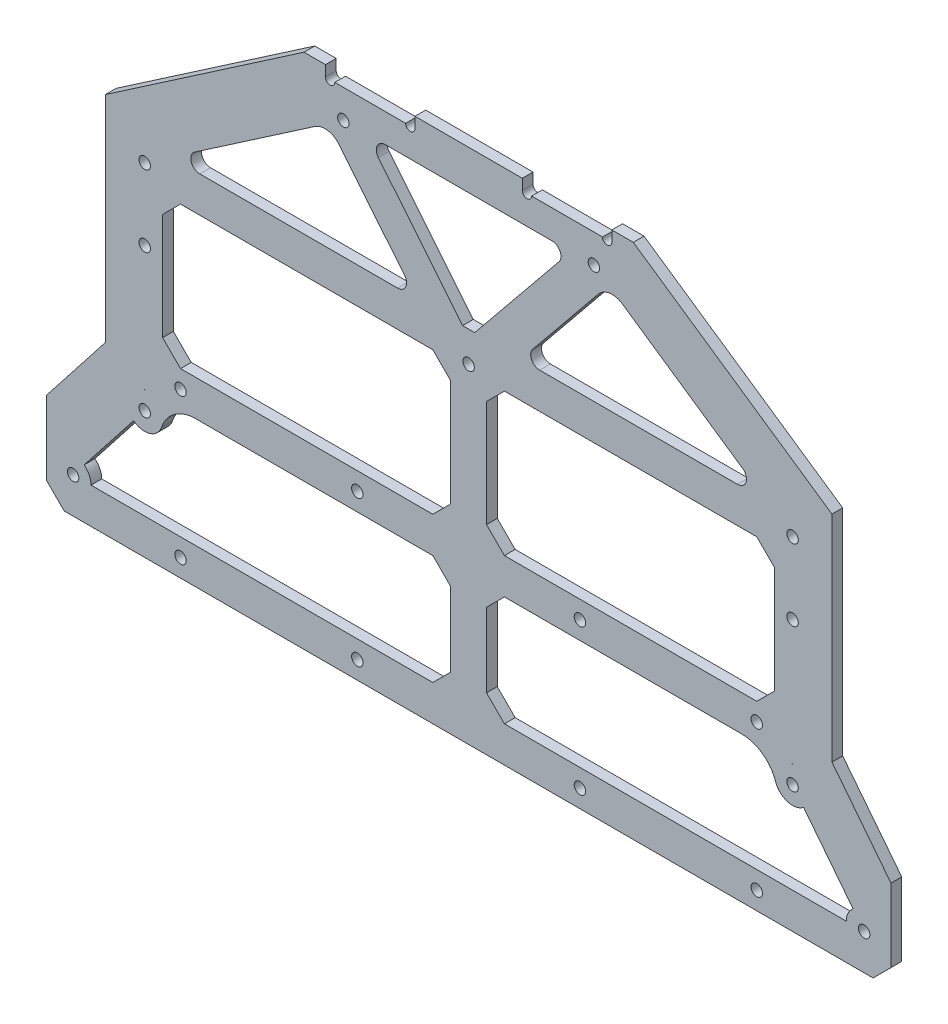
from build123d import *

# Parameters (mm, degrees)
SKETCH_1_R           = 1.6
EXTRUDE_1_DEPTH      = 3
EXTRUDE_2_DEPTH      = 3
CUT_EXTRUDE_2_REACH  = 5
SKETCH_6_W           = 3
SKETCH_6_H           = 46.5
CUT_EXTRUDE_3_DEPTH  = 3.5
SKETCH_7_W           = 3
SKETCH_7_H           = 46.5
CUT_EXTRUDE_4_DEPTH  = 3.5
CUT_EXTRUDE_5_REACH  = 5
CUT_EXTRUDE_6_REACH  = 5
SKETCH_11_W          = 181
SKETCH_11_H          = 10
EXTRUDE_2_2_DEPTH    = 3
CUT_EXTRUDE_7_REACH  = 5
SKETCH_12_R          = 1.6
EXTRUDE_4_DEPTH      = 3
CUT_EXTRUDE_8_REACH  = 5
SKETCH_15_W          = 10
SKETCH_15_H          = 100.5
EXTRUDE_5_DEPTH      = 3
CUT_EXTRUDE_9_REACH  = 5
SKETCH_16_R          = 1.6
SKETCH_17_W          = 181
SKETCH_17_H          = 10
EXTRUDE_6_DEPTH      = 3
CUT_EXTRUDE_10_REACH = 5
SKETCH_18_R          = 1.6
CUT_EXTRUDE_11_REACH = 5
SKETCH_19_R          = 1.6
EXTRUDE_3_DEPTH      = 3
FILLET_1_R           = 10
CHAMFER_1_SIZE       = 5
CHAMFER_2_SIZE       = 5
CUT_EXTRUDE_12_REACH = 5
CUT_EXTRUDE_13_REACH = 5
SKETCH_22_R          = 1.6
FILLET_2_R           = 5
FILLET_3_R           = 2.5
EXTRUDE_4_2_DEPTH    = 3
CUT_EXTRUDE_14_REACH = 5
SKETCH_24_R          = 1.6
CHAMFER_3_SIZE       = 5


with BuildPart() as part:
    # 草图1 → 凸台-拉伸1 (new body)
    with BuildSketch(Plane.XY):
        Polygon((-121.5, -87), (-121.5, -123.5), (-121.5, -133.5), (121.5, -133.5), (121.5, -123.5), (121.5, -87), (101.5, -87), (101.5, -27), (46, -27), (46, 11), (-46, 11), (-46, -27), (-101.5, -27), (-101.5, -87), align=None)
        with Locations((-110.5, -123.5)):
            Circle(SKETCH_1_R, mode=Mode.SUBTRACT)
        with Locations((-90.5, -98)):
            Circle(SKETCH_1_R, mode=Mode.SUBTRACT)
        with Locations((-90.5, -38)):
            Circle(SKETCH_1_R, mode=Mode.SUBTRACT)
        with Locations((-35, 0)):
            Circle(SKETCH_1_R, mode=Mode.SUBTRACT)
        with Locations((110.5, -123.5)):
            Circle(SKETCH_1_R, mode=Mode.SUBTRACT)
        with Locations((90.5, -98)):
            Circle(SKETCH_1_R, mode=Mode.SUBTRACT)
        with Locations((90.5, -38)):
            Circle(SKETCH_1_R, mode=Mode.SUBTRACT)
        with Locations((35, 0)):
            Circle(SKETCH_1_R, mode=Mode.SUBTRACT)
    extrude(amount=EXTRUDE_1_DEPTH)

    # 草图4 → Extrude 2 (add)
    with BuildSketch(Plane(origin=(0, 0, 0), x_dir=(-1, 0, 0), z_dir=(0, 0, -1))):
        Polygon((-101.5, -27), (-46, 11), (-46, -27), align=None)
        Polygon((46, 11), (101.5, -27), (46, -27), align=None)
    extrude(amount=-EXTRUDE_2_DEPTH)

    # 草图5 → 切除-拉伸2 (cut, up to next)
    with BuildSketch(Plane.XY.offset(3), mode=Mode.PRIVATE) as cut_extrude_2_sk1:
        with BuildLine():
            Line((-86.374375572, -35.175248139), (-39.125624428, -2.824751861))
            ThreePointArc((-39.125624428, -2.824751861), (-33.521507887, -4.776406711), (-30, 0))
            Line((-30, 0), (30, 0))
            ThreePointArc((30, 0), (33.521507887, -4.776406711), (39.125624428, -2.824751861))
            Line((39.125624428, -2.824751861), (86.374375572, -35.175248139))
            ThreePointArc((86.374375572, -35.175248139), (86.077118626, -40.331977776), (90.5, -43))
            Line((90.5, -43), (90.5, -93))
            ThreePointArc((90.5, -93), (85.773937398, -99.632278249), (93.585699676, -101.934267087))
            Line((93.585699676, -101.934267087), (107.414300324, -119.565732913))
            ThreePointArc((107.414300324, -119.565732913), (106.003974067, -121.312364105), (105.5, -123.5))
            Line((105.5, -123.5), (-105.5, -123.5))
            ThreePointArc((-105.5, -123.5), (-106.003974067, -121.312364105), (-107.414300324, -119.565732913))
            Line((-107.414300324, -119.565732913), (-93.585699676, -101.934267087))
            ThreePointArc((-93.585699676, -101.934267087), (-85.773937398, -99.632278249), (-90.5, -93))
            Line((-90.5, -93), (-90.5, -43))
            ThreePointArc((-90.5, -43), (-86.077118626, -40.331977776), (-86.374375572, -35.175248139))
        make_face()
    cut_extrude_2_tool1 = extrude(cut_extrude_2_sk1.sketch, amount=-CUT_EXTRUDE_2_REACH, mode=Mode.PRIVATE) & part.part
    add(cut_extrude_2_tool1.solids().sort_by_distance((0, -68.124521, 3))[0], mode=Mode.SUBTRACT)

    # 草图6 → 切除-拉伸3 (cut)
    with BuildSketch(Plane.ZY.offset(121.5)):
        with Locations((1.5, -110.25)):
            Rectangle(SKETCH_6_W, SKETCH_6_H)
    extrude(amount=-CUT_EXTRUDE_3_DEPTH, mode=Mode.SUBTRACT)

    # 草图7 → 切除-拉伸4 (cut)
    with BuildSketch(Plane(origin=(121.5, 0, 0), x_dir=(0, 0, -1), z_dir=(1, 0, 0))):
        with Locations((-1.5, -110.25)):
            Rectangle(SKETCH_7_W, SKETCH_7_H)
    extrude(amount=-CUT_EXTRUDE_4_DEPTH, mode=Mode.SUBTRACT)

    # 草图8 → 切除-拉伸5 (cut, up to next)
    with BuildSketch(Plane.XY.offset(3), mode=Mode.PRIVATE) as cut_extrude_5_sk1:
        Polygon((-101.5, -87), (-118, -108.0375), (-118, -87), align=None)
    cut_extrude_5_tool1 = extrude(cut_extrude_5_sk1.sketch, amount=-CUT_EXTRUDE_5_REACH, mode=Mode.PRIVATE) & part.part
    add(cut_extrude_5_tool1.solids().sort_by_distance((-112.5, -94.0125, 3))[0], mode=Mode.SUBTRACT)

    # 草图9 → 切除-拉伸6 (cut, up to next)
    with BuildSketch(Plane.XY.offset(3), mode=Mode.PRIVATE) as cut_extrude_6_sk1:
        Polygon((101.5, -87), (118, -108.0375), (118, -87), align=None)
    cut_extrude_6_tool1 = extrude(cut_extrude_6_sk1.sketch, amount=-CUT_EXTRUDE_6_REACH, mode=Mode.PRIVATE) & part.part
    add(cut_extrude_6_tool1.solids().sort_by_distance((112.5, -94.0125, 3))[0], mode=Mode.SUBTRACT)

    # 草图11 → Extrude 2 2 (add)
    with BuildSketch(Plane.XY.offset(3)):
        with Locations((0, -38)):
            Rectangle(SKETCH_11_W, SKETCH_11_H)
    extrude(amount=-EXTRUDE_2_2_DEPTH)

    # 草图12 → 切除-拉伸7 (cut, up to next)
    with BuildSketch(Plane(origin=(0, 0, 0), x_dir=(-1, 0, 0), z_dir=(0, 0, -1)), mode=Mode.PRIVATE) as cut_extrude_7_sk1:
        with Locations((-90.5, -38)):
            Circle(SKETCH_12_R)
    cut_extrude_7_tool1 = extrude(cut_extrude_7_sk1.sketch, amount=-CUT_EXTRUDE_7_REACH, mode=Mode.PRIVATE) & part.part
    add(cut_extrude_7_tool1.solids().sort_by_distance((90.5, -38, 0))[0], mode=Mode.SUBTRACT)
    # 草图12 → 切除-拉伸7 (cut, up to next)
    with BuildSketch(Plane(origin=(0, 0, 0), x_dir=(-1, 0, 0), z_dir=(0, 0, -1)), mode=Mode.PRIVATE) as cut_extrude_7_sk2:
        with Locations((90.5, -38)):
            Circle(SKETCH_12_R)
    cut_extrude_7_tool2 = extrude(cut_extrude_7_sk2.sketch, amount=-CUT_EXTRUDE_7_REACH, mode=Mode.PRIVATE) & part.part
    add(cut_extrude_7_tool2.solids().sort_by_distance((-90.5, -38, 0))[0], mode=Mode.SUBTRACT)

    # 草图13 → Extrude 4 (add)
    with BuildSketch(Plane(origin=(0, 0, 0), x_dir=(-1, 0, 0), z_dir=(0, 0, -1))):
        Polygon((-38.877810019, -3.156356992), (0, -50.920523586), (38.877810019, -3.156356992), (31.122189981, 3.156356992), (0, -35.079476414), (-31.122189981, 3.156356992), align=None)
    extrude(amount=-EXTRUDE_4_DEPTH)

    # 草图14 → 切除-拉伸8 (cut, up to next)
    with BuildSketch(Plane.XY.offset(3), mode=Mode.PRIVATE) as cut_extrude_8_sk1:
        Polygon((0, -50.920523586), (6.446937803, -43), (-6.446937803, -43), align=None)
    cut_extrude_8_tool1 = extrude(cut_extrude_8_sk1.sketch, amount=-CUT_EXTRUDE_8_REACH, mode=Mode.PRIVATE) & part.part
    add(cut_extrude_8_tool1.solids().sort_by_distance((0, -45.640175, 3))[0], mode=Mode.SUBTRACT)

    # 草图15 → 拉伸-薄壁5 (add)
    with BuildSketch(Plane.XY.offset(3)):
        with Locations((0, -83.25)):
            Rectangle(SKETCH_15_W, SKETCH_15_H)
    extrude(amount=-EXTRUDE_5_DEPTH)

    # 草图16 → 切除-拉伸9 (cut, up to next)
    with BuildSketch(Plane(origin=(0, 0, 0), x_dir=(-1, 0, 0), z_dir=(0, 0, -1)), mode=Mode.PRIVATE) as cut_extrude_9_sk1:
        with Locations((80.5, -128.5)):
            Circle(SKETCH_16_R)
    cut_extrude_9_tool1 = extrude(cut_extrude_9_sk1.sketch, amount=-CUT_EXTRUDE_9_REACH, mode=Mode.PRIVATE) & part.part
    add(cut_extrude_9_tool1.solids().sort_by_distance((-80.5, -128.5, 0))[0], mode=Mode.SUBTRACT)
    # 草图16 → 切除-拉伸9 (cut, up to next)
    with BuildSketch(Plane(origin=(0, 0, 0), x_dir=(-1, 0, 0), z_dir=(0, 0, -1)), mode=Mode.PRIVATE) as cut_extrude_9_sk2:
        with Locations((31.1, -128.5)):
            Circle(SKETCH_16_R)
    cut_extrude_9_tool2 = extrude(cut_extrude_9_sk2.sketch, amount=-CUT_EXTRUDE_9_REACH, mode=Mode.PRIVATE) & part.part
    add(cut_extrude_9_tool2.solids().sort_by_distance((-31.1, -128.5, 0))[0], mode=Mode.SUBTRACT)
    # 草图16 → 切除-拉伸9 (cut, up to next)
    with BuildSketch(Plane(origin=(0, 0, 0), x_dir=(-1, 0, 0), z_dir=(0, 0, -1)), mode=Mode.PRIVATE) as cut_extrude_9_sk3:
        with Locations((-80.5, -128.5)):
            Circle(SKETCH_16_R)
    cut_extrude_9_tool3 = extrude(cut_extrude_9_sk3.sketch, amount=-CUT_EXTRUDE_9_REACH, mode=Mode.PRIVATE) & part.part
    add(cut_extrude_9_tool3.solids().sort_by_distance((80.5, -128.5, 0))[0], mode=Mode.SUBTRACT)
    # 草图16 → 切除-拉伸9 (cut, up to next)
    with BuildSketch(Plane(origin=(0, 0, 0), x_dir=(-1, 0, 0), z_dir=(0, 0, -1)), mode=Mode.PRIVATE) as cut_extrude_9_sk4:
        with Locations((-31.1, -128.5)):
            Circle(SKETCH_16_R)
    cut_extrude_9_tool4 = extrude(cut_extrude_9_sk4.sketch, amount=-CUT_EXTRUDE_9_REACH, mode=Mode.PRIVATE) & part.part
    add(cut_extrude_9_tool4.solids().sort_by_distance((31.1, -128.5, 0))[0], mode=Mode.SUBTRACT)

    # 草图17 → 拉伸-薄壁6 (add)
    with BuildSketch(Plane(origin=(0, 0, 0), x_dir=(-1, 0, 0), z_dir=(0, 0, -1))):
        with Locations((0, -87.8)):
            Rectangle(SKETCH_17_W, SKETCH_17_H)
    extrude(amount=-EXTRUDE_6_DEPTH)

    # 草图18 → 切除-拉伸10 (cut, up to next)
    with BuildSketch(Plane(origin=(0, 0, 0), x_dir=(-1, 0, 0), z_dir=(0, 0, -1)), mode=Mode.PRIVATE) as cut_extrude_10_sk1:
        with Locations((31.1, -87.8)):
            Circle(SKETCH_18_R)
    cut_extrude_10_tool1 = extrude(cut_extrude_10_sk1.sketch, amount=-CUT_EXTRUDE_10_REACH, mode=Mode.PRIVATE) & part.part
    add(cut_extrude_10_tool1.solids().sort_by_distance((-31.1, -87.8, 0))[0], mode=Mode.SUBTRACT)
    # 草图18 → 切除-拉伸10 (cut, up to next)
    with BuildSketch(Plane(origin=(0, 0, 0), x_dir=(-1, 0, 0), z_dir=(0, 0, -1)), mode=Mode.PRIVATE) as cut_extrude_10_sk2:
        with Locations((80.5, -87.8)):
            Circle(SKETCH_18_R)
    cut_extrude_10_tool2 = extrude(cut_extrude_10_sk2.sketch, amount=-CUT_EXTRUDE_10_REACH, mode=Mode.PRIVATE) & part.part
    add(cut_extrude_10_tool2.solids().sort_by_distance((-80.5, -87.8, 0))[0], mode=Mode.SUBTRACT)
    # 草图18 → 切除-拉伸10 (cut, up to next)
    with BuildSketch(Plane(origin=(0, 0, 0), x_dir=(-1, 0, 0), z_dir=(0, 0, -1)), mode=Mode.PRIVATE) as cut_extrude_10_sk3:
        with Locations((-80.5, -87.8)):
            Circle(SKETCH_18_R)
    cut_extrude_10_tool3 = extrude(cut_extrude_10_sk3.sketch, amount=-CUT_EXTRUDE_10_REACH, mode=Mode.PRIVATE) & part.part
    add(cut_extrude_10_tool3.solids().sort_by_distance((80.5, -87.8, 0))[0], mode=Mode.SUBTRACT)
    # 草图18 → 切除-拉伸10 (cut, up to next)
    with BuildSketch(Plane(origin=(0, 0, 0), x_dir=(-1, 0, 0), z_dir=(0, 0, -1)), mode=Mode.PRIVATE) as cut_extrude_10_sk4:
        with Locations((-31.1, -87.8)):
            Circle(SKETCH_18_R)
    cut_extrude_10_tool4 = extrude(cut_extrude_10_sk4.sketch, amount=-CUT_EXTRUDE_10_REACH, mode=Mode.PRIVATE) & part.part
    add(cut_extrude_10_tool4.solids().sort_by_distance((31.1, -87.8, 0))[0], mode=Mode.SUBTRACT)

    # 草图19 → 切除-拉伸11 (cut, up to next)
    with BuildSketch(Plane(origin=(0, 0, 0), x_dir=(-1, 0, 0), z_dir=(0, 0, -1)), mode=Mode.PRIVATE) as cut_extrude_11_sk1:
        with Locations((-35, 0)):
            Circle(SKETCH_19_R)
    cut_extrude_11_tool1 = extrude(cut_extrude_11_sk1.sketch, amount=-CUT_EXTRUDE_11_REACH, mode=Mode.PRIVATE) & part.part
    add(cut_extrude_11_tool1.solids().sort_by_distance((35, 0, 0))[0], mode=Mode.SUBTRACT)
    # 草图19 → 切除-拉伸11 (cut, up to next)
    with BuildSketch(Plane(origin=(0, 0, 0), x_dir=(-1, 0, 0), z_dir=(0, 0, -1)), mode=Mode.PRIVATE) as cut_extrude_11_sk2:
        with Locations((35, 0)):
            Circle(SKETCH_19_R)
    cut_extrude_11_tool2 = extrude(cut_extrude_11_sk2.sketch, amount=-CUT_EXTRUDE_11_REACH, mode=Mode.PRIVATE) & part.part
    add(cut_extrude_11_tool2.solids().sort_by_distance((-35, 0, 0))[0], mode=Mode.SUBTRACT)

    # 草图20 → 凸台-拉伸3 (add)
    with BuildSketch(Plane(origin=(0, 0, 0), x_dir=(-1, 0, 0), z_dir=(0, 0, -1))):
        Polygon((-85.773937398, -99.632278249), (-83.414218512, -92.8), (-90.5, -92.8), align=None)
        Polygon((90.5, -92.8), (85.773937398, -99.632278249), (83.414218512, -92.8), align=None)
    extrude(amount=-EXTRUDE_3_DEPTH)

    # 圆角1
    fillet_1_edges = [part.edges().sort_by_distance(p)[0] for p in [
        (83.414218512, -92.8, 1.5),
        (-83.414218512, -92.8, 1.5),
    ]]
    fillet(fillet_1_edges, radius=FILLET_1_R)

    # 倒角1
    chamfer_1_edges = [part.edges().sort_by_distance(p)[0] for p in [
        (-118, -133.5, 1.5),
        (118, -133.5, 1.5),
    ]]
    chamfer(chamfer_1_edges, length=CHAMFER_1_SIZE)

    # 倒角2
    chamfer_2_edges = [part.edges().sort_by_distance(p)[0] for p in [
        (-90.5, -43, 1.5),
        (90.5, -43, 1.5),
        (-5, -43, 1.5),
        (5, -43, 1.5),
        (5, -123.5, 1.5),
        (-5, -123.5, 1.5),
        (-5, -92.8, 1.5),
        (-5, -82.8, 1.5),
        (90.5, -82.8, 1.5),
        (5, -82.8, 1.5),
        (5, -92.8, 1.5),
        (-90.5, -82.8, 1.5),
    ]]
    chamfer(chamfer_2_edges, length=CHAMFER_2_SIZE)

    # 草图21 → 切除-拉伸12 (cut, up to next)
    with BuildSketch(Plane(origin=(0, 0, 0), x_dir=(-1, 0, 0), z_dir=(0, 0, -1)), mode=Mode.PRIVATE) as cut_extrude_12_sk1:
        with BuildLine():
            Line((-15, 8), (-15, 11))
            Line((-15, 11), (-40, 11))
            Line((-40, 11), (-40, 8))
            ThreePointArc((-40, 8), (-38.7, 6.7), (-37.4, 8))
            Line((-37.4, 8), (-17.6, 8))
            ThreePointArc((-17.6, 8), (-16.3, 6.7), (-15, 8))
        make_face()
    cut_extrude_12_tool1 = extrude(cut_extrude_12_sk1.sketch, amount=-CUT_EXTRUDE_12_REACH, mode=Mode.PRIVATE) & part.part
    add(cut_extrude_12_tool1.solids().sort_by_distance((27.5, 9.364359, 0))[0], mode=Mode.SUBTRACT)
    # 草图21 → 切除-拉伸12 (cut, up to next)
    with BuildSketch(Plane(origin=(0, 0, 0), x_dir=(-1, 0, 0), z_dir=(0, 0, -1)), mode=Mode.PRIVATE) as cut_extrude_12_sk2:
        with BuildLine():
            Line((37.4, 8), (17.6, 8))
            ThreePointArc((17.6, 8), (16.3, 6.7), (15, 8))
            Line((15, 8), (15, 11))
            Line((15, 11), (40, 11))
            Line((40, 11), (40, 8))
            ThreePointArc((40, 8), (38.7, 6.7), (37.4, 8))
        make_face()
    cut_extrude_12_tool2 = extrude(cut_extrude_12_sk2.sketch, amount=-CUT_EXTRUDE_12_REACH, mode=Mode.PRIVATE) & part.part
    add(cut_extrude_12_tool2.solids().sort_by_distance((-27.5, 9.364359, 0))[0], mode=Mode.SUBTRACT)

    # 草图22 → 切除-拉伸13 (cut, up to next)
    with BuildSketch(Plane(origin=(0, 0, 0), x_dir=(-1, 0, 0), z_dir=(0, 0, -1)), mode=Mode.PRIVATE) as cut_extrude_13_sk1:
        with Locations((0, -41.5)):
            Circle(SKETCH_22_R)
    cut_extrude_13_tool1 = extrude(cut_extrude_13_sk1.sketch, amount=-CUT_EXTRUDE_13_REACH, mode=Mode.PRIVATE) & part.part
    add(cut_extrude_13_tool1.solids().sort_by_distance((0, -41.5, 0))[0], mode=Mode.SUBTRACT)

    # 圆角2
    fillet_2_edges = [part.edges().sort_by_distance(p)[0] for p in [
        (-39.125624428, -2.824751861, 1.5),
        (39.125624428, -2.824751861, 1.5),
    ]]
    fillet(fillet_2_edges, radius=FILLET_2_R)

    # 圆角3
    fillet_3_edges = [part.edges().sort_by_distance(p)[0] for p in [
        (83.197368421, -33, 1.5),
        (-83.197368421, -33, 1.5),
        (14.586472686, -33, 1.5),
        (-14.586472686, -33, 1.5),
        (28.553062197, 0, 1.5),
        (-28.553062197, 0, 1.5),
    ]]
    fillet(fillet_3_edges, radius=FILLET_3_R)

    # 草图23 → Extrude 4 2 (add)
    with BuildSketch(Plane(origin=(0, 0, 0), x_dir=(-1, 0, 0), z_dir=(0, 0, -1))):
        Polygon((-85.5, -43), (-85.5, -82.8), (-90.5, -77.8), (-90.5, -48), align=None)
        Polygon((85.5, -82.8), (85.5, -43), (90.5, -48), (90.5, -77.8), align=None)
    extrude(amount=-EXTRUDE_4_2_DEPTH)

    # 草图24 → 切除-拉伸14 (cut, up to next)
    with BuildSketch(Plane(origin=(0, 0, 0), x_dir=(-1, 0, 0), z_dir=(0, 0, -1)), mode=Mode.PRIVATE) as cut_extrude_14_sk1:
        with Locations((-90.5, -58)):
            Circle(SKETCH_24_R)
    cut_extrude_14_tool1 = extrude(cut_extrude_14_sk1.sketch, amount=-CUT_EXTRUDE_14_REACH, mode=Mode.PRIVATE) & part.part
    add(cut_extrude_14_tool1.solids().sort_by_distance((90.5, -58, 0))[0], mode=Mode.SUBTRACT)
    # 草图24 → 切除-拉伸14 (cut, up to next)
    with BuildSketch(Plane(origin=(0, 0, 0), x_dir=(-1, 0, 0), z_dir=(0, 0, -1)), mode=Mode.PRIVATE) as cut_extrude_14_sk2:
        with Locations((90.5, -58)):
            Circle(SKETCH_24_R)
    cut_extrude_14_tool2 = extrude(cut_extrude_14_sk2.sketch, amount=-CUT_EXTRUDE_14_REACH, mode=Mode.PRIVATE) & part.part
    add(cut_extrude_14_tool2.solids().sort_by_distance((-90.5, -58, 0))[0], mode=Mode.SUBTRACT)

    # 倒角3
    chamfer_3_edges = [part.edges().sort_by_distance(p)[0] for p in [
        (85.5, -43, 1.5),
        (-85.5, -43, 1.5),
        (85.5, -82.8, 1.5),
        (-85.5, -82.8, 1.5),
    ]]
    chamfer(chamfer_3_edges, length=CHAMFER_3_SIZE)


solid = part.part
